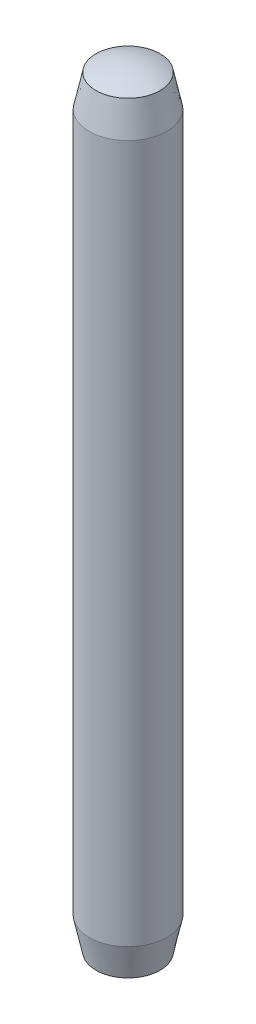
from build123d import *

# Parameters (mm, degrees)
SKETCH1_R           = 0.5
BOSS_EXTRUDE1_DEPTH = 10


with BuildPart() as part:
    # Sketch1 → Boss-Extrude1 (new body)
    with BuildSketch(Plane(origin=(0, 0, 0), x_dir=(1, 0, 0), z_dir=(0, 1, 0))):
        Circle(SKETCH1_R)
    extrude(amount=BOSS_EXTRUDE1_DEPTH)

    # Sketch2 → Cut-Revolve2 (revolve, cut)
    with BuildSketch(Plane.XY):
        with BuildLine():
            Line((0.5, 9.866025404), (0.5, 10.1))
            Line((0.5, 10.1), (0, 10.1))
            Line((0, 10.1), (0, 10))
            ThreePointArc((0, 10), (0.258819045, 9.965925826), (0.5, 9.866025404))
        make_face()
        with BuildLine():
            Line((0.5, -0.1), (0, -0.1))
            Line((0, -0.1), (0, 0))
            ThreePointArc((0, 0), (0.258819045, 0.034074174), (0.5, 0.133974596))
            Line((0.5, 0.133974596), (0.5, -0.1))
        make_face()
    revolve(axis=Axis((0, 0, 0), (0, 1, 0)), mode=Mode.SUBTRACT)

    # Sketch3 → Cut-Revolve3 (revolve, cut)
    with BuildSketch(Plane.XY):
        with BuildLine():
            Line((-0.5, 9.5), (-0.41266406, 9.910883293))
            ThreePointArc((-0.41266406, 9.910883293), (-0.456882894, 9.889526852), (-0.5, 9.866025404))
            Line((-0.5, 9.866025404), (-0.5, 9.5))
        make_face()
        with BuildLine():
            Line((-0.5, 0.133974596), (-0.5, 0.5))
            Line((-0.5, 0.5), (-0.41266406, 0.089116707))
            ThreePointArc((-0.41266406, 0.089116707), (-0.456882894, 0.110473148), (-0.5, 0.133974596))
        make_face()
    revolve(axis=Axis((0, 0, 0), (0, 1, 0)), mode=Mode.SUBTRACT)


solid = part.part
